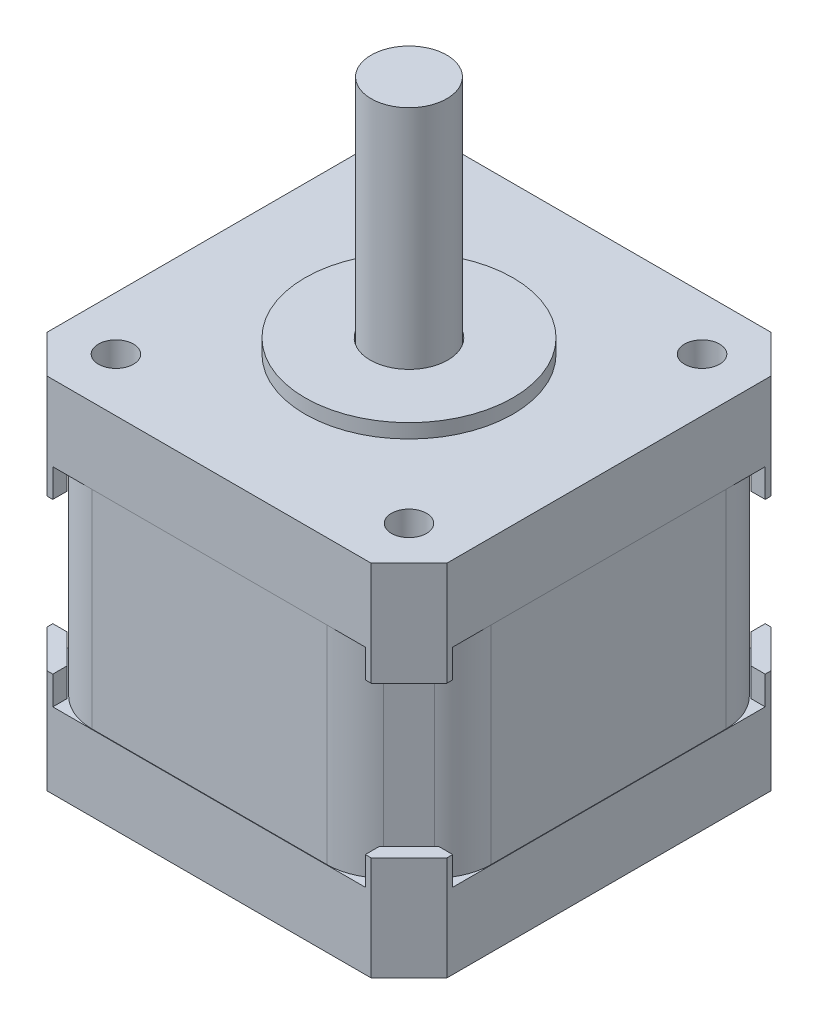
from build123d import *

# Parameters (mm, degrees)
ESBO_O1_W              = 42.3
ESBO_O1_H              = 42.3
UPPERBODY_DEPTH        = 8
CHANFRO1_SIZE          = 4
ESBO_O2_R              = 11
ESBO_O2_R_2            = 4.1
LITTLETOPCIRCLE_DEPTH  = 1.5
ESBO_O3_R              = 1.853680608
MOUNTINGHOLES_DEPTH    = 25
PADR_OCIRCULAR1_COUNT  = 4
LITTLEMETALTABS_DEPTH  = 3
PADR_OCIRCULAR2_COUNT  = 4
MIDDLEBODY_DEPTH       = 22
FILETE1_R              = 6
ESBO_O9_W              = 42.3
ESBO_O9_H              = 42.3
BOTTOMBODY_DEPTH       = 8
CHANFRO5_SIZE          = 4
LITTLEMETALTABS2_DEPTH = 3
PADR_OCIRCULAR3_COUNT  = 4
ESBO_O4_R              = 4
BOSS_EXTRUDE1_DEPTH    = 25.4


with BuildPart() as part:
    # Esboço1 → UpperBody (new body)
    with BuildSketch(Plane(origin=(0, 0, 0), x_dir=(1, 0, 0), z_dir=(0, 1, 0))):
        Rectangle(ESBO_O1_W, ESBO_O1_H)
    extrude(amount=UPPERBODY_DEPTH)

    # Chanfro1
    chanfro1_edges = [part.edges().sort_by_distance(p)[0] for p in [
        (-21.15, 4, 21.15),
        (21.15, 4, -21.15),
        (-21.15, 4, -21.15),
        (21.15, 4, 21.15),
    ]]
    chamfer(chanfro1_edges, length=CHANFRO1_SIZE)

    # Esboço2 → LittleTopCircle (add)
    with BuildSketch(Plane(origin=(0, 8, 0), x_dir=(1, 0, 0), z_dir=(0, 1, 0))):
        Circle(ESBO_O2_R)
        Circle(ESBO_O2_R_2, mode=Mode.SUBTRACT)
    extrude(amount=LITTLETOPCIRCLE_DEPTH)

    # Esboço3 → MountingHoles (cut)
    with BuildSketch(Plane(origin=(0, 8, 0), x_dir=(1, 0, 0), z_dir=(0, 1, 0))):
        with Locations((-15.5, 15.5)):
            Circle(ESBO_O3_R)
    mountingholes = extrude(amount=-MOUNTINGHOLES_DEPTH, mode=Mode.SUBTRACT)

    # PadrãoCircular1: MountingHoles ×4 about axis
    padr_ocircular1_axis = Axis((0, 8, 0), (0, 1, 0))
    for i in range(1, PADR_OCIRCULAR1_COUNT):
        add(mountingholes.rotate(padr_ocircular1_axis, i * 360 / PADR_OCIRCULAR1_COUNT), mode=Mode.SUBTRACT)

    # Esboço7 → LittleMetalTabs (add)
    with BuildSketch(Plane.XZ):
        Polygon((-19.65, -16.528679656), (-21.15, -16.528679656), (-21.15, -17.15), (-17.15, -21.15), (-16.528679656, -21.15), (-16.528679656, -19.65), align=None)
    littlemetaltabs = extrude(amount=LITTLEMETALTABS_DEPTH)

    # PadrãoCircular2: LittleMetalTabs ×4 about axis
    padr_ocircular2_axis = Axis((0, 9.5, 0), (0, 1, 0))
    for i in range(1, PADR_OCIRCULAR2_COUNT):
        add(littlemetaltabs.rotate(padr_ocircular2_axis, i * 360 / PADR_OCIRCULAR2_COUNT))

    # Esboço8 → MiddleBody (add)
    with BuildSketch(Plane.XZ):
        Polygon((-14.9, 21.1), (14.9, 21.1), (21.1, 14.9), (21.1, -14.9), (14.9, -21.1), (-14.9, -21.1), (-21.1, -14.9), (-21.1, 14.9), align=None)
    extrude(amount=MIDDLEBODY_DEPTH)

    # Filete1
    filete1_edges = [part.edges().sort_by_distance(p)[0] for p in [
        (-21.1, -11, -14.9),
        (-21.1, -11, 14.9),
        (-14.9, -11, 21.1),
        (14.9, -11, 21.1),
        (-14.9, -11, -21.1),
        (21.1, -11, 14.9),
        (14.9, -11, -21.1),
        (21.1, -11, -14.9),
    ]]
    fillet(filete1_edges, radius=FILETE1_R)

    # Esboço9 → BottomBody (add)
    with BuildSketch(Plane.XZ.offset(22)):
        Rectangle(ESBO_O9_W, ESBO_O9_H)
    extrude(amount=BOTTOMBODY_DEPTH)

    # Chanfro5
    chanfro5_edges = [part.edges().sort_by_distance(p)[0] for p in [
        (21.15, -26, 21.15),
        (21.15, -26, -21.15),
        (-21.15, -26, 21.15),
        (-21.15, -26, -21.15),
    ]]
    chamfer(chanfro5_edges, length=CHANFRO5_SIZE)

    # Esboço10 → LittleMetalTabs2 (add)
    with BuildSketch(Plane(origin=(0, -22, 0), x_dir=(1, 0, 0), z_dir=(0, 1, 0))):
        Polygon((-16.528679656, -21.15), (-16.528679656, -19.65), (-19.65, -16.528679656), (-21.15, -16.528679656), (-21.15, -17.15), (-17.15, -21.15), align=None)
    littlemetaltabs2 = extrude(amount=LITTLEMETALTABS2_DEPTH)

    # PadrãoCircular3: LittleMetalTabs2 ×4 about axis
    padr_ocircular3_axis = Axis((0, -30, 0), (0, 1, 0))
    for i in range(1, PADR_OCIRCULAR3_COUNT):
        add(littlemetaltabs2.rotate(padr_ocircular3_axis, i * 360 / PADR_OCIRCULAR3_COUNT))

    # Esboço4 → Boss-Extrude1 (add)
    with BuildSketch(Plane(origin=(0, 8, 0), x_dir=(1, 0, 0), z_dir=(0, 1, 0))):
        Circle(ESBO_O4_R)
    extrude(amount=BOSS_EXTRUDE1_DEPTH)


solid = part.part
